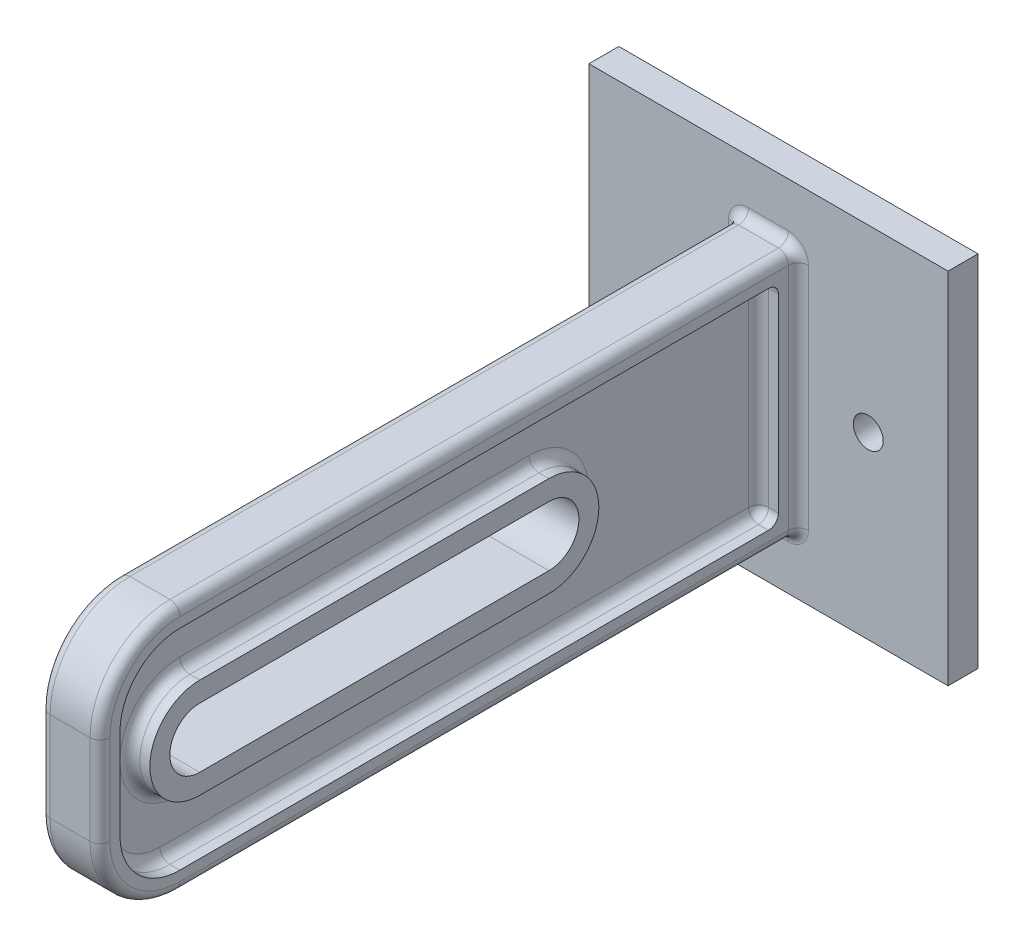
from build123d import *

# Parameters (mm, degrees)
SKETCH1_W           = 36
SKETCH1_H           = 36
BOSS_EXTRUDE1_DEPTH = 3
SKETCH2_R           = 1.5
CUT_EXTRUDE1_DEPTH  = 3
SKETCH3_W           = 6
SKETCH3_H           = 25
BOSS_EXTRUDE2_DEPTH = 70
CUT_EXTRUDE2_DEPTH  = 70
FILLET1_R           = 8
CUT_EXTRUDE3_DEPTH  = 2
FILLET2_R           = 1
FILLET4_R           = 1
FILLET5_R           = 1
FILLET6_R           = 1
FILLET7_R           = 1


with BuildPart() as part:
    # Sketch1 → Boss-Extrude1 (new body)
    with BuildSketch(Plane.XY):
        Rectangle(SKETCH1_W, SKETCH1_H)
    extrude(amount=BOSS_EXTRUDE1_DEPTH)

    # Sketch2 → Cut-Extrude1 (cut)
    with BuildSketch(Plane.XY.offset(3)):
        with Locations((-10, 0)):
            Circle(SKETCH2_R)
        with Locations((10, 0)):
            Circle(SKETCH2_R)
    extrude(amount=-CUT_EXTRUDE1_DEPTH, mode=Mode.SUBTRACT)

    # Sketch3 → Boss-Extrude2 (add)
    with BuildSketch(Plane.XY.offset(3)):
        Rectangle(SKETCH3_W, SKETCH3_H)
    extrude(amount=BOSS_EXTRUDE2_DEPTH)

    # Sketch4 → Cut-Extrude2 (cut)
    with BuildSketch(Plane(origin=(3, 0, 0), x_dir=(0, 0, -1), z_dir=(1, 0, 0))):
        with BuildLine():
            Line((-63, 3), (-28, 3))
            ThreePointArc((-28, 3), (-25, 0), (-28, -3))
            Line((-28, -3), (-63, -3))
            ThreePointArc((-63, -3), (-66, 0), (-63, 3))
        make_face()
    extrude(amount=-CUT_EXTRUDE2_DEPTH, mode=Mode.SUBTRACT)

    # Fillet1
    fillet1_edges = [part.edges().sort_by_distance(p)[0] for p in [
        (0, -12.5, 73),
        (0, 12.5, 73),
    ]]
    fillet(fillet1_edges, radius=FILLET1_R)

    # Sketch5 → Cut-Extrude3 (cut)
    with BuildSketch(Plane(origin=(3, 0, 0), x_dir=(0, 0, -1), z_dir=(1, 0, 0))):
        with BuildLine():
            Line((-5, 10.5), (-65, 10.5))
            ThreePointArc((-65, 10.5), (-69.242640687, 8.742640687), (-71, 4.5))
            Line((-71, 4.5), (-71, -4.5))
            ThreePointArc((-71, -4.5), (-69.242640687, -8.742640687), (-65, -10.5))
            Line((-65, -10.5), (-5, -10.5))
            Line((-5, -10.5), (-5, 10.5))
        make_face()
        with BuildLine():
            Line((-28, 5), (-63, 5))
            ThreePointArc((-63, 5), (-68, 0), (-63, -5))
            Line((-63, -5), (-28, -5))
            ThreePointArc((-28, -5), (-23, 0), (-28, 5))
        make_face(mode=Mode.SUBTRACT)
    cut_extrude3 = extrude(amount=-CUT_EXTRUDE3_DEPTH, mode=Mode.SUBTRACT)

    # Mirror1: Cut-Extrude3 across plane
    add(cut_extrude3.mirror(Plane(origin=(0, 0, 0), x_dir=(0, 0, 1), z_dir=(1, 0, 0))), mode=Mode.SUBTRACT)

    # Fillet2
    fillet2_edges = [part.edges().sort_by_distance(p)[0] for p in [
        (-3, 0, 3),
        (0, -12.5, 3),
        (3, 0, 3),
        (0, 12.5, 3),
        (-3, 0, 73),
        (3, 0, 73),
        (-3, -12.5, 34),
        (-3, 12.5, 34),
        (-3, -10.156854249, 70.656854249),
        (-3, 10.156854249, 70.656854249),
        (3, 12.5, 34),
        (3, -12.5, 34),
        (3, -10.156854249, 70.656854249),
        (3, 10.156854249, 70.656854249),
    ]]
    fillet(fillet2_edges, radius=FILLET2_R)

    # Fillet4
    fillet4_edges = [part.edges().sort_by_distance(p)[0] for p in [
        (1, 0, 5),
        (2, 10.5, 5),
        (1, -10.5, 35),
        (2, -10.5, 5),
        (1, -8.742640687, 69.242640687),
        (1, 0, 71),
        (1, 8.742640687, 69.242640687),
        (1, 10.5, 35),
    ]]
    fillet(fillet4_edges, radius=FILLET4_R)

    # Fillet5
    fillet5_edges = [part.edges().sort_by_distance(p)[0] for p in [
        (1, -5, 45.5),
        (1, 0, 23),
        (1, 5, 45.5),
        (1, 0, 68),
    ]]
    fillet(fillet5_edges, radius=FILLET5_R)

    # Fillet6
    fillet6_edges = [part.edges().sort_by_distance(p)[0] for p in [
        (-1, 0, 5),
        (-1, 10.5, 35),
        (-1, 8.742640687, 69.242640687),
        (-1, 0, 71),
        (-1, -8.742640687, 69.242640687),
        (-1, -10.5, 35),
        (-2, -10.5, 5),
        (-2, 10.5, 5),
    ]]
    fillet(fillet6_edges, radius=FILLET6_R)

    # Fillet7
    fillet7_edges = [part.edges().sort_by_distance(p)[0] for p in [
        (-1, 0, 23),
        (-1, 5, 45.5),
        (-1, 0, 68),
        (-1, -5, 45.5),
    ]]
    fillet(fillet7_edges, radius=FILLET7_R)


solid = part.part
